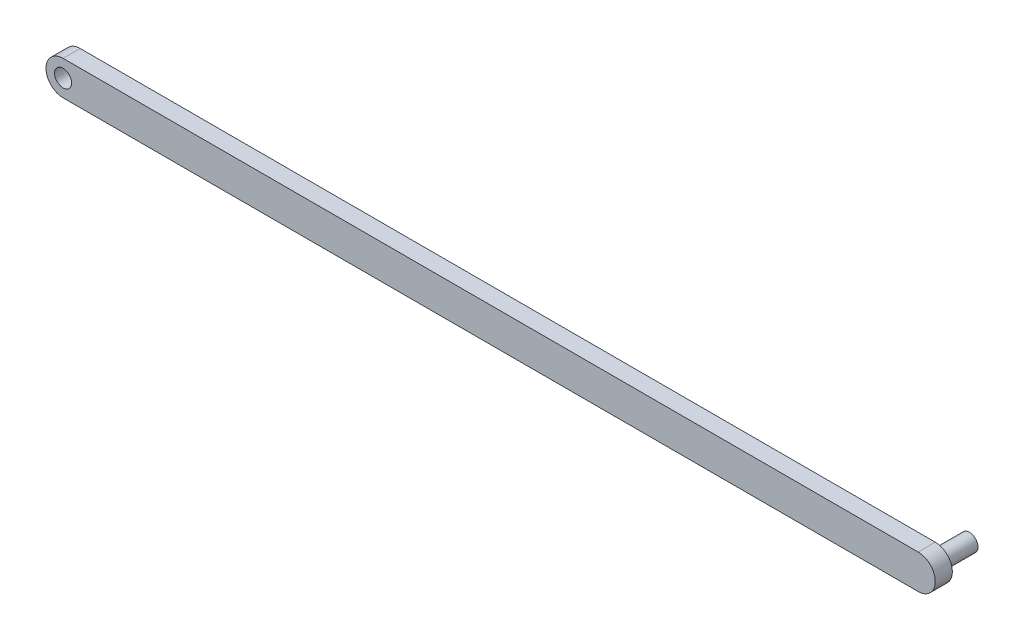
from build123d import *

# Parameters (mm, degrees)
EXTRUDE_1_DEPTH     = 2
SKETCH_2_R          = 1
EXTRUDE_2_DEPTH     = 4
SKETCH_3_R          = 1
CUT_EXTRUDE_1_DEPTH = 4


with BuildPart() as part:
    # 草图1 → 凸台-拉伸1 (new body)
    with BuildSketch(Plane.XY):
        with BuildLine():
            Line((-59.140028095, -2), (40.859971905, -2))
            ThreePointArc((40.859971905, -2), (42.859971905, 0), (40.859971905, 2))
            Line((40.859971905, 2), (-59.140028095, 2))
            ThreePointArc((-59.140028095, 2), (-61.140028095, 0), (-59.140028095, -2))
        make_face()
    extrude(amount=EXTRUDE_1_DEPTH)

    # 草图2 → 凸台-拉伸2 (add)
    with BuildSketch(Plane(origin=(0, 0, 0), x_dir=(-1, 0, 0), z_dir=(0, 0, -1))):
        with Locations((-40.859971905, 0)):
            Circle(SKETCH_2_R)
    extrude(amount=EXTRUDE_2_DEPTH)

    # 草图3 → 切除-拉伸1 (cut)
    with BuildSketch(Plane(origin=(0, 0, 0), x_dir=(-1, 0, 0), z_dir=(0, 0, -1))):
        with Locations((59.140028095, 0)):
            Circle(SKETCH_3_R)
    extrude(amount=-CUT_EXTRUDE_1_DEPTH, mode=Mode.SUBTRACT)


solid = part.part
